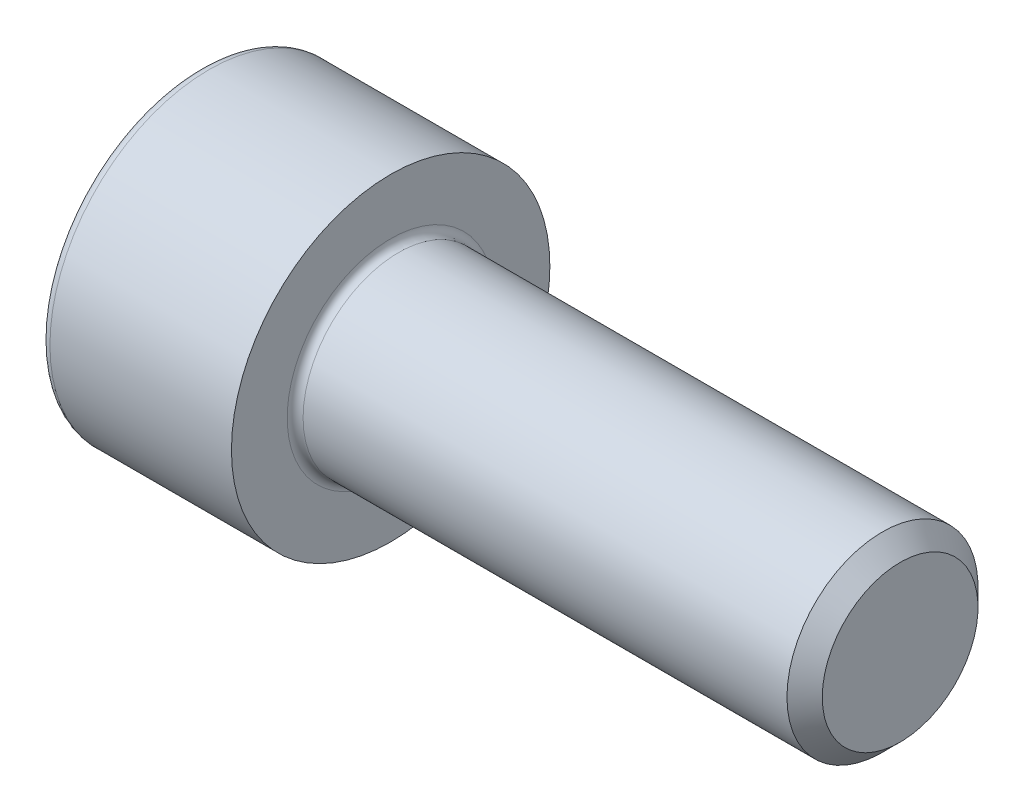
from build123d import *

# Parameters (mm, degrees)
FILLET1_R   = 0.25
FILLET2_R   = 0.3
HEX_2_DEPTH = 3


with BuildPart() as part:
    # BodySke → Base-Revolve (revolve)
    with BuildSketch(Plane.XY):
        Polygon((0, 0), (0, 5), (6, 5), (6, 3), (21.4455, 3), (22, 2.4455), (22, 0), align=None)
    revolve(axis=Axis((-31.75, 0, 0), (1, 0, 0)))

    # Fillet1
    fillet1_edges = [part.edges().sort_by_distance(p)[0] for p in [
        (6, -3, 0),
    ]]
    fillet(fillet1_edges, radius=FILLET1_R)

    # Fillet2
    fillet2_edges = [part.edges().sort_by_distance(p)[0] for p in [
        (0, -5, 0),
    ]]
    fillet(fillet2_edges, radius=FILLET2_R)

    # Sketch2 → Hex-PreBroach (revolve, cut)
    with BuildSketch(Plane.XY):
        Polygon((0, 2.542), (3, 2.542), (4.467624384, 0), (0, 0), align=None)
    revolve(axis=Axis((0, 0, 0), (1, 0, 0)), mode=Mode.SUBTRACT)

    # Sketch3 → Hex 2 (cut)
    with BuildSketch(Plane(origin=(0, 0, 0), x_dir=(0, 0.5, 0.866025404), z_dir=(-1, 0, 0))):
        Polygon((1.467624384, 2.542), (-1.467624384, 2.542), (-2.935248769, 0), (-1.467624384, -2.542), (1.467624384, -2.542), (2.935248769, 0), align=None)
    extrude(amount=-HEX_2_DEPTH, mode=Mode.SUBTRACT)


solid = part.part
